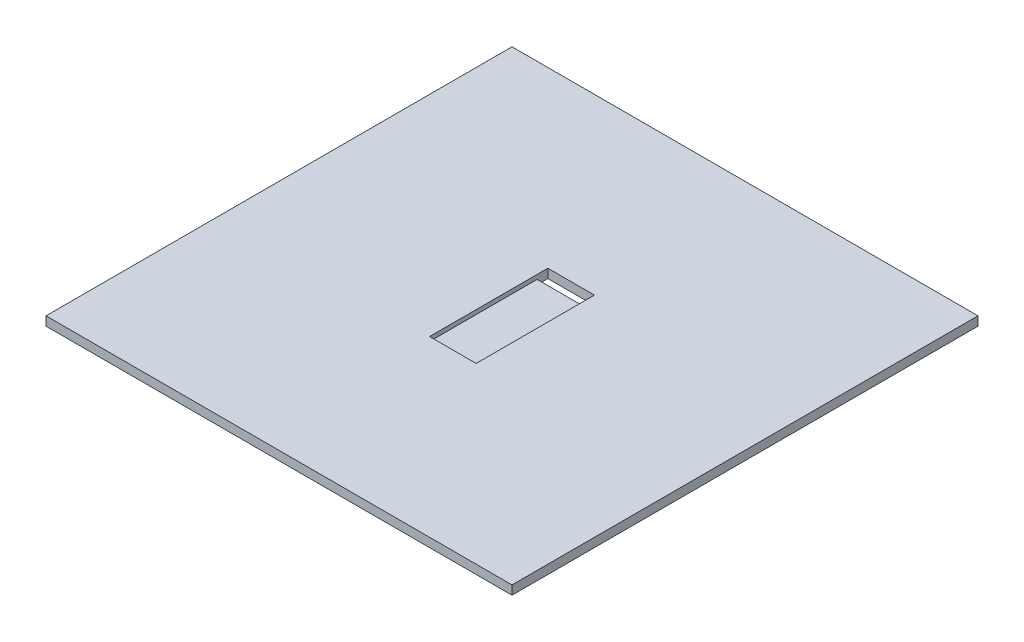
from build123d import *

# Parameters (mm, degrees)
SKETCH2_W           = 130
SKETCH2_H           = 130
BOSS_EXTRUDE1_DEPTH = 2.5
SKETCH3_W           = 13
SKETCH3_H           = 33
CUT_EXTRUDE1_DEPTH  = 1.2
SKETCH4_W           = 13
SKETCH4_H           = 3
CUT_EXTRUDE2_DEPTH  = 2.3


with BuildPart() as part:
    # Sketch2 → Boss-Extrude1 (new body)
    with BuildSketch(Plane(origin=(0, 0, 0), x_dir=(1, 0, 0), z_dir=(0, 1, 0))):
        Rectangle(SKETCH2_W, SKETCH2_H)
    extrude(amount=BOSS_EXTRUDE1_DEPTH)

    # Sketch3 → Cut-Extrude1 (cut)
    with BuildSketch(Plane(origin=(0, 2.5, 0), x_dir=(1, 0, 0), z_dir=(0, 1, 0))):
        Rectangle(SKETCH3_W, SKETCH3_H)
    extrude(amount=-CUT_EXTRUDE1_DEPTH, mode=Mode.SUBTRACT)

    # Sketch4 → Cut-Extrude2 (cut, through all)
    with BuildSketch(Plane(origin=(0, 1.3, 0), x_dir=(1, 0, 0), z_dir=(0, 1, 0))):
        with Locations((0, 15)):
            Rectangle(SKETCH4_W, SKETCH4_H)
    extrude(amount=-CUT_EXTRUDE2_DEPTH, mode=Mode.SUBTRACT)


solid = part.part
